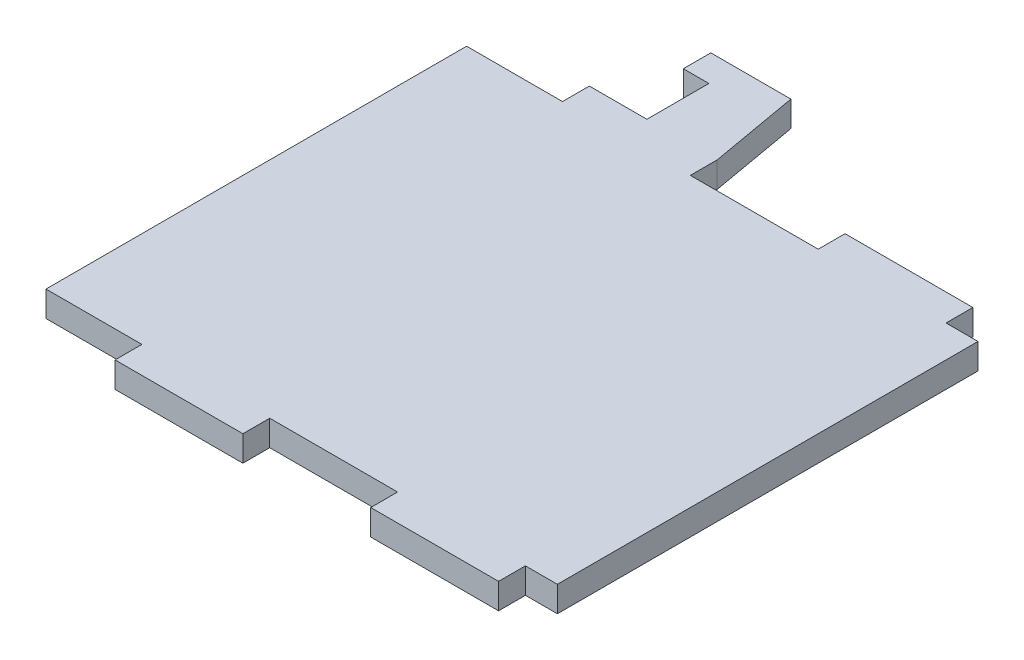
from build123d import *

# Parameters (mm, degrees)
BOSS_EXTRU_1_DEPTH = 4


with BuildPart() as part:
    # Esquisse1 → Boss.-Extru.1 (new body)
    with BuildSketch(Plane(origin=(0, 0, 0), x_dir=(1, 0, 0), z_dir=(0, 1, 0))):
        Polygon((0, 0), (15, 0), (15, -4.2), (35, -4.2), (35, 0), (55, 0), (55, -4.2), (75, -4.2), (75, 0), (80, 0), (80, 65.8), (75, 65.8), (75, 70), (55, 70), (55, 65.8), (35, 65.8), (35, 70), (32.53142227, 84), (20, 84), (20, 79.7), (24, 79.7), (24, 70), (15, 70), (15, 65.8), (0, 65.8), align=None)
    extrude(amount=BOSS_EXTRU_1_DEPTH)


solid = part.part
